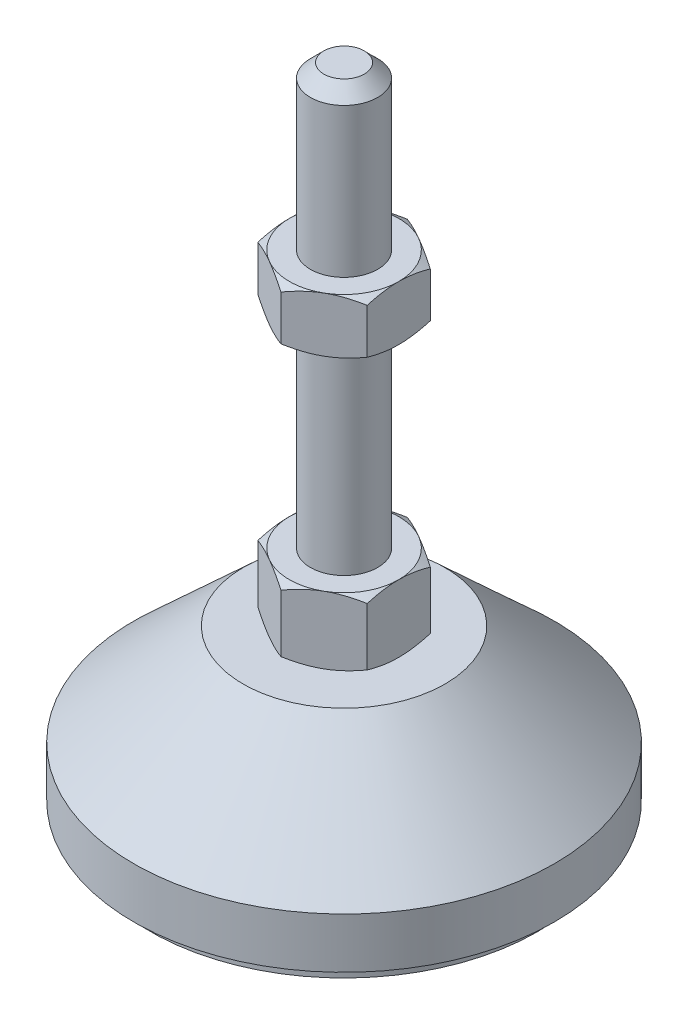
from build123d import *

# Parameters (mm, degrees)
EXTRUDE_1_DEPTH = 8
EXTRUDE_2_DEPTH = 6.5


with BuildPart() as part:
    # Эскиз1 → Повернуть1 (revolve)
    with BuildSketch(Plane.XY, mode=Mode.PRIVATE) as revolve_1_sk:
        Polygon((0, 0), (-23, 0), (-23, 2), (-25, 2), (-25, 8), (-12, 20), (-4, 20), (-4, 28), (-4, 76.4), (-2.4, 78), (0, 78), align=None)
    revolve(revolve_1_sk.sketch.rotate(Axis((0, 0, 0), (0, 1, 0)), 180), axis=Axis((0, 0, 0), (0, 1, 0)))  # turned: the seam where the file's is

    # Эскиз2 → Бобышка-Вытянуть1 (add)
    with BuildSketch(Plane(origin=(0, 20, 0), x_dir=(1, 0, 0), z_dir=(0, 1, 0))):
        Polygon((0, 7.505553499), (-6.5, 3.75277675), (-6.5, -3.75277675), (0, -7.505553499), (6.5, -3.75277675), (6.5, 3.75277675), align=None)
    extrude(amount=EXTRUDE_1_DEPTH)

    # Эскиз3 → Бобышка-Вытянуть2 (add)
    with BuildSketch(Plane(origin=(0, 52.2, 0), x_dir=(1, 0, 0), z_dir=(0, 1, 0))):
        Polygon((6.5, 3.75277675), (0, 7.505553499), (-6.5, 3.75277675), (-6.5, -3.75277675), (0, -7.505553499), (6.5, -3.75277675), align=None)
    extrude(amount=EXTRUDE_2_DEPTH)

    # Эскиз4 → Вырез-Повернуть2 (revolve, cut)
    with BuildSketch(Plane.XY, mode=Mode.PRIVATE) as cut_revolve_2_sk:
        Polygon((-12.129165125, 58.7), (-6.5, 58.7), (-12.129165125, 55.45), align=None)
        Polygon((-12.129165125, 52.2), (-12.129165125, 55.45), (-6.5, 52.2), align=None)
        Polygon((-13.42820323, 28), (-13.42820323, 24), (-6.5, 28), align=None)
        Polygon((-13.42820323, 24), (-13.42820323, 20), (-6.5, 20), align=None)
    revolve(cut_revolve_2_sk.sketch.rotate(Axis((0, 78, 0), (0, 1, 0)), 180), axis=Axis((0, 78, 0), (0, 1, 0)), mode=Mode.SUBTRACT)  # turned: the seam where the file's is


solid = part.part
